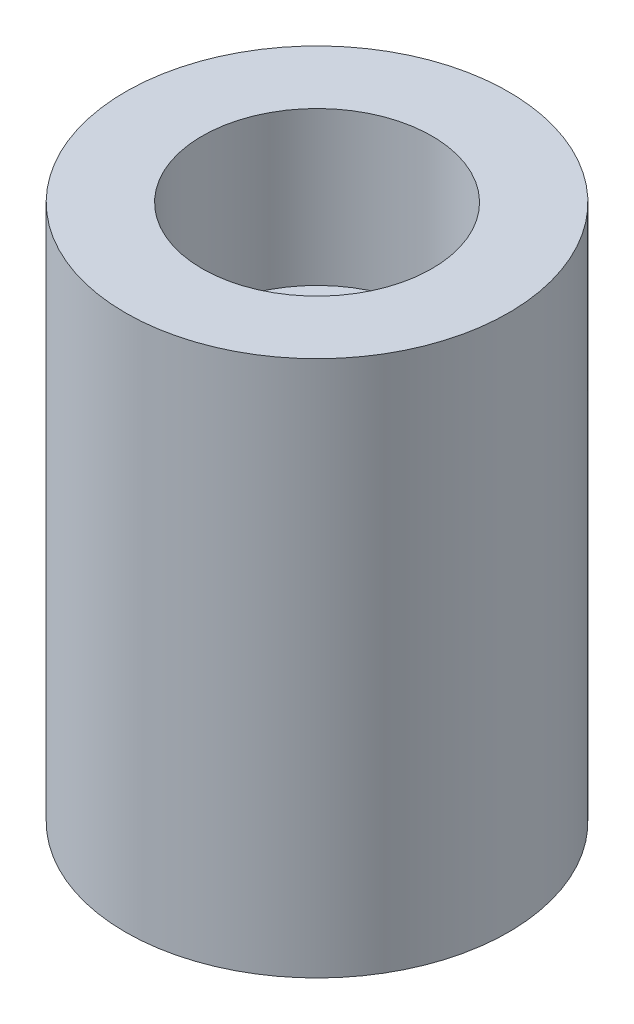
from build123d import *

# Parameters (mm, degrees)
SKETCH1_R           = 50
BOSS_EXTRUDE1_DEPTH = 140
SKETCH2_R           = 30
CUT_EXTRUDE1_DEPTH  = 40
SKETCH3_R           = 10
CUT_EXTRUDE2_DEPTH  = 80


with BuildPart() as part:
    # Sketch1 → Boss-Extrude1 (new body)
    with BuildSketch(Plane(origin=(0, 0, 0), x_dir=(1, 0, 0), z_dir=(0, 1, 0))):
        with Locations(Location((0, 0, 0), (0, 0, 270))):  # turned: the seam where the file's is
            Circle(SKETCH1_R)
    extrude(amount=BOSS_EXTRUDE1_DEPTH)

    # Sketch2 → Cut-Extrude1 (cut)
    with BuildSketch(Plane(origin=(0, 140, 0), x_dir=(1, 0, 0), z_dir=(0, 1, 0))):
        with Locations(Location((0, 0, 0), (0, 0, 270))):  # turned: the seam where the file's is
            Circle(SKETCH2_R)
    extrude(amount=-CUT_EXTRUDE1_DEPTH, mode=Mode.SUBTRACT)

    # Sketch3 → Cut-Extrude2 (cut)
    with BuildSketch(Plane(origin=(0, 100, 0), x_dir=(1, 0, 0), z_dir=(0, 1, 0))):
        with Locations(Location((0, 0, 0), (0, 0, 270))):  # turned: the seam where the file's is
            Circle(SKETCH3_R)
    extrude(amount=-CUT_EXTRUDE2_DEPTH, mode=Mode.SUBTRACT)


solid = part.part
